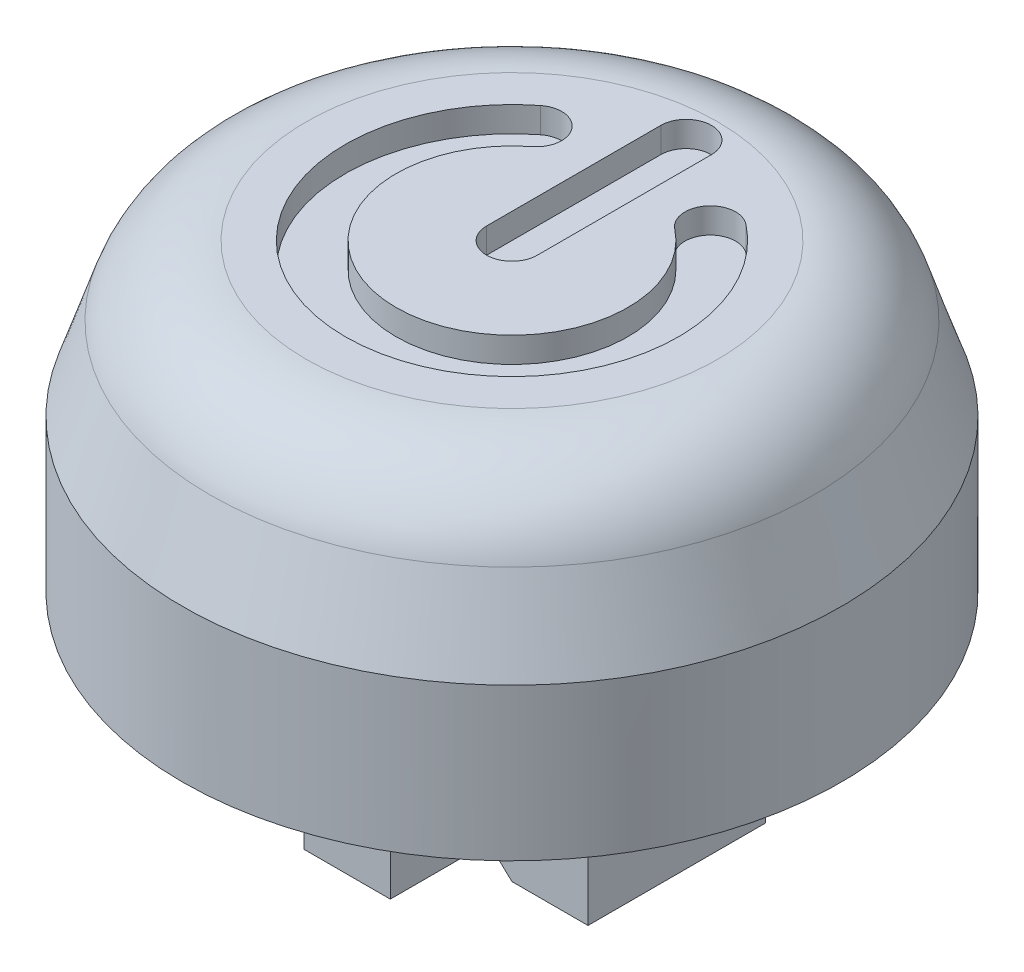
from build123d import *

# Parameters (mm, degrees)
SKETCH1_R           = 6.5
BOSS_EXTRUDE1_DEPTH = 3
SKETCH2_R           = 5.5
FILLET1_R           = 2
SKETCH3_R           = 0.5
CUT_EXTRUDE1_DEPTH  = 0.5
SKETCH4_R           = 5
CUT_EXTRUDE2_DEPTH  = 1.8
SKETCH5_W           = 1.5
SKETCH5_H           = 3.5
SKETCH5_W_2         = 1.7
SKETCH5_H_2         = 1.5
BOSS_EXTRUDE3_DEPTH = 5
BOSS_EXTRUDE4_DEPTH = 3.5
FILLET2_R           = 1


with BuildPart() as part:
    # Sketch1 → Boss-Extrude1 (new body)
    with BuildSketch(Plane(origin=(0, 0, 0), x_dir=(1, 0, 0), z_dir=(0, 1, 0))):
        Circle(SKETCH1_R)
    extrude(amount=BOSS_EXTRUDE1_DEPTH)

    # Sketch2 → section 0 of loft1
    with BuildSketch(Plane(origin=(0, 6, 0), x_dir=(1, 0, 0), z_dir=(0, 1, 0)), mode=Mode.PRIVATE) as loft1_s0:
        Circle(SKETCH2_R)
    # loft up to a face of the part (loft1)
    loft([loft1_s0.sketch, part.faces().sort_by_distance((0, 3, 0))[0]])

    # Fillet1
    fillet1_edges = [part.edges().sort_by_distance(p)[0] for p in [
        (-5.5, 6, 0),
    ]]
    fillet(fillet1_edges, radius=FILLET1_R)

    # Sketch3 → Cut-Extrude1 (cut)
    with BuildSketch(Plane(origin=(0, 6, 0), x_dir=(1, 0, 0), z_dir=(0, 1, 0))):
        with BuildLine():
            Line((0.5, 0), (0.5, 3.435004881))
            ThreePointArc((0.5, 3.435004881), (0, 3.935004881), (-0.5, 3.435004881))
            Line((-0.5, 3.435004881), (-0.5, 0))
            ThreePointArc((-0.5, 0), (0, -0.5), (0.5, 0))
        make_face()
        with BuildLine():
            ThreePointArc((-1.408185783, 1.802395609), (-2.110021897, 1.888570248), (-2.023847258, 2.590406363))
            ThreePointArc((-2.023847258, 2.590406363), (0, -3.287272859), (2.023847258, 2.590406363))
            ThreePointArc((2.023847258, 2.590406363), (2.165413544, 2.415586559), (2.21601652, 2.196400986))
            ThreePointArc((2.21601652, 2.196400986), (1.935202094, 1.747003963), (1.408185783, 1.802395609))
            ThreePointArc((1.408185783, 1.802395609), (0, -2.287272859), (-1.408185783, 1.802395609))
        make_face()
        with Locations((1.71601652, 2.196400986)):
            Circle(SKETCH3_R)
        with Locations((-1.71601652, 2.196400986)):
            Circle(SKETCH3_R)
    extrude(amount=-CUT_EXTRUDE1_DEPTH, mode=Mode.SUBTRACT)

    # Sketch4 → Cut-Extrude2 (cut)
    with BuildSketch(Plane.XZ):
        Circle(SKETCH4_R)
    extrude(amount=-CUT_EXTRUDE2_DEPTH, mode=Mode.SUBTRACT)

    # Sketch5 → Boss-Extrude3 (add)
    with BuildSketch(Plane.XZ.offset(-1.8)):
        with Locations((2.5, 0)):
            Rectangle(SKETCH5_W, SKETCH5_H)
        with Locations((0, -2.5)):
            Rectangle(SKETCH5_W_2, SKETCH5_H_2)
        with Locations((-2.5, 0)):
            Rectangle(SKETCH5_W, SKETCH5_H)
        with Locations((0, 2.5)):
            Rectangle(SKETCH5_W_2, SKETCH5_H_2)
    extrude(amount=BOSS_EXTRUDE3_DEPTH)

    # Sketch6 → Boss-Extrude4 (add)
    with BuildSketch(Plane.XY.offset(1.75)):
        Polygon((1.75, -3.2), (1, -2.5), (1.75, -2.5), align=None)
    boss_extrude4 = extrude(amount=-BOSS_EXTRUDE4_DEPTH)

    # Mirror1: Boss-Extrude4 across plane
    add(boss_extrude4.mirror(Plane(origin=(0, 0, 0), x_dir=(0, 0, 1), z_dir=(1, 0, 0))))

    # Fillet2
    fillet2_edges = [part.edges().sort_by_distance(p)[0] for p in [
        (3.25, 1.8, 0),
        (0, 1.8, -3.25),
        (-3.25, 1.8, 0),
        (0, 1.8, 3.25),
    ]]
    fillet(fillet2_edges, radius=FILLET2_R)


solid = part.part
